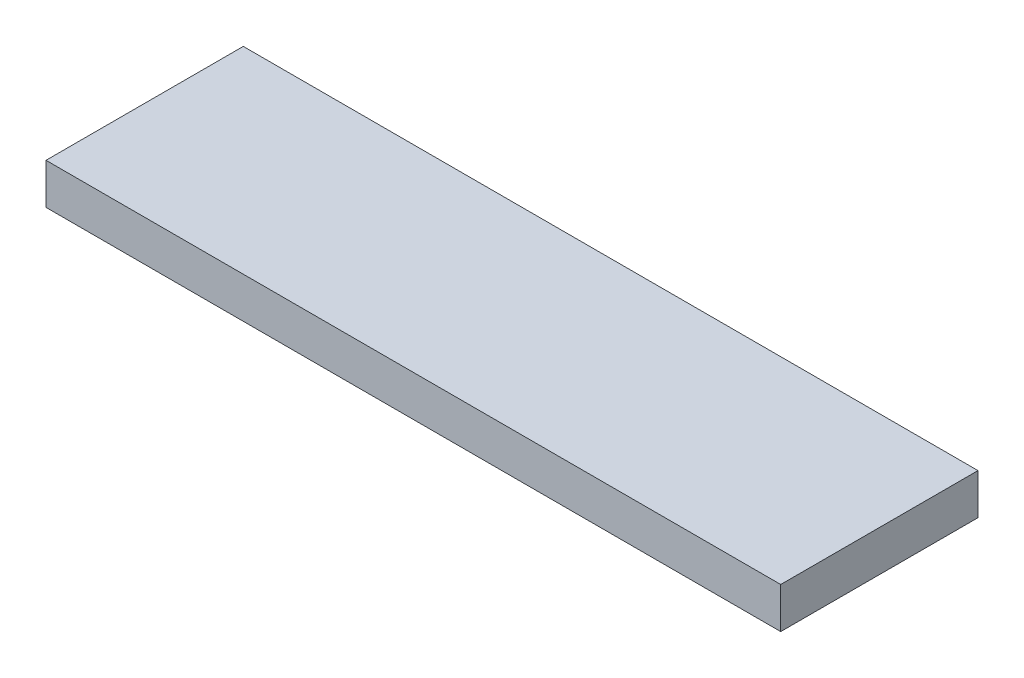
from build123d import *

# Parameters (mm, degrees)
SKETCH1_W           = 685.8
SKETCH1_H           = 184.15
BOSS_EXTRUDE1_DEPTH = 38.1


with BuildPart() as part:
    # Sketch1 → Boss-Extrude1 (new body)
    with BuildSketch(Plane(origin=(0, 0, 0), x_dir=(1, 0, 0), z_dir=(0, 1, 0))):
        with Locations((342.9, 92.075)):
            Rectangle(SKETCH1_W, SKETCH1_H)
    extrude(amount=BOSS_EXTRUDE1_DEPTH)


solid = part.part
